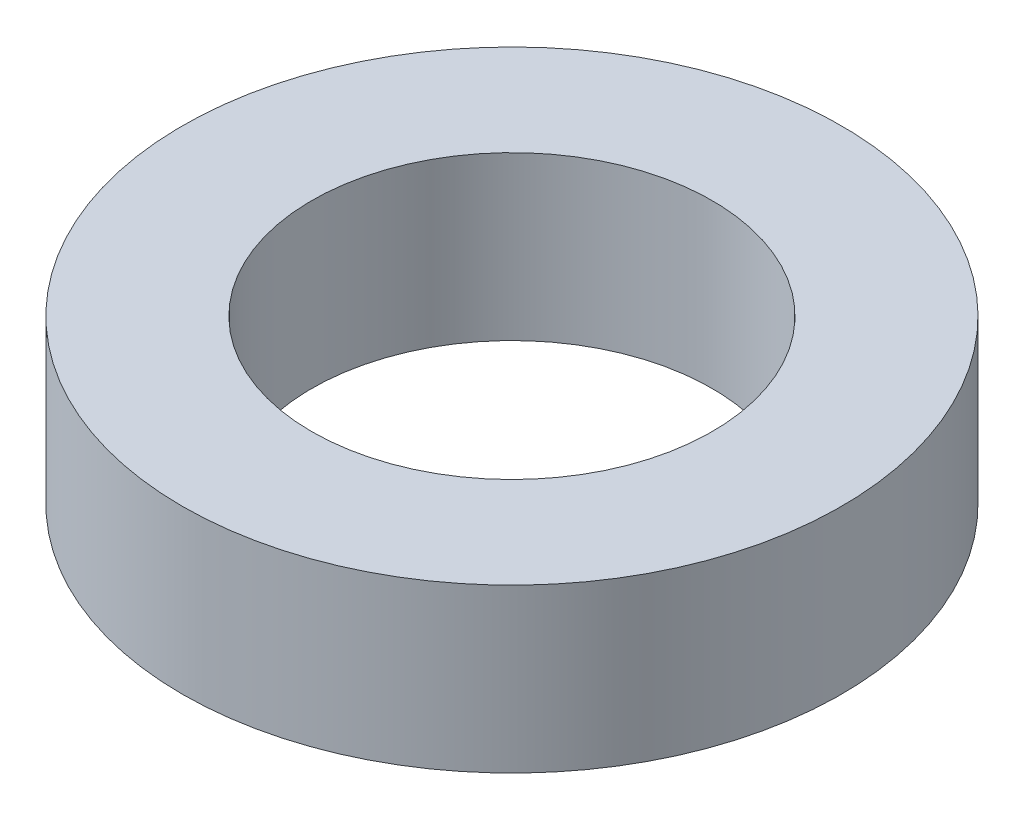
from build123d import *

# Parameters (mm, degrees)
SKETCH_1_R      = 20.25
SKETCH_1_R_2    = 12.3
EXTRUDE_1_DEPTH = 10


with BuildPart() as part:
    # Эскиз1 → Бобышка-Вытянуть1 (new body)
    with BuildSketch(Plane(origin=(0, 0, 0), x_dir=(1, 0, 0), z_dir=(0, 1, 0))):
        Circle(SKETCH_1_R)
        Circle(SKETCH_1_R_2, mode=Mode.SUBTRACT)
    extrude(amount=EXTRUDE_1_DEPTH)


solid = part.part
